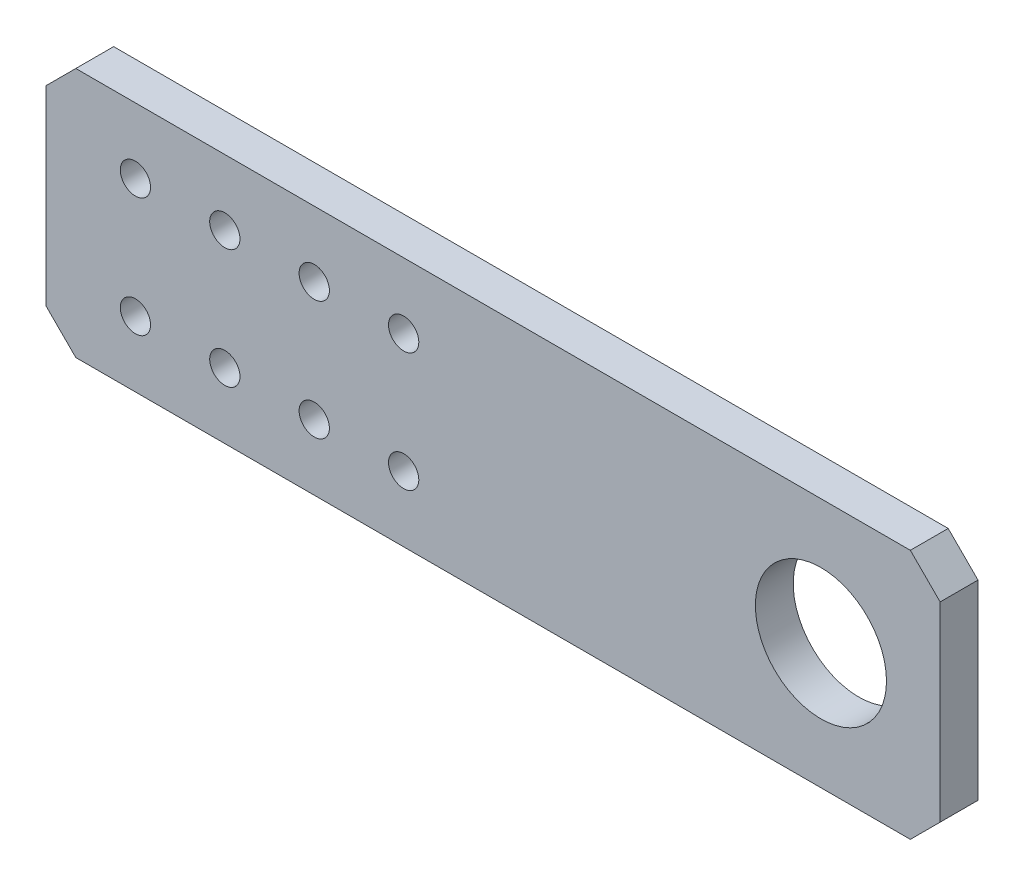
from build123d import *

# Parameters (mm, degrees)
SKETCH1_W           = 200
SKETCH1_H           = 42
BOSS_EXTRUDE1_DEPTH = 6.35
SKETCH4_R           = 2.286
CUT_EXTRUDE3_DEPTH  = 7.35
CHAMFER1_SIZE       = 5
SKETCH9_R           = 11
CUT_EXTRUDE8_DEPTH  = 7.35
SKETCH12_R          = 2.286
CUT_EXTRUDE11_DEPTH = 7.35
SKETCH13_R          = 2.286
SKETCH13_R_2        = 2.54
CUT_EXTRUDE12_DEPTH = 10


with BuildPart() as part:
    # Sketch1 → Boss-Extrude1 (new body)
    with BuildSketch(Plane.XY):
        Rectangle(SKETCH1_W, SKETCH1_H)
    extrude(amount=BOSS_EXTRUDE1_DEPTH)

    # Sketch4 → Cut-Extrude3 (cut, through all)
    with BuildSketch(Plane.XY.offset(6.35)):
        with Locations((-76, 0)):
            Circle(SKETCH4_R)
    extrude(amount=-CUT_EXTRUDE3_DEPTH, mode=Mode.SUBTRACT)

    # Chamfer1
    chamfer1_edges = [part.edges().sort_by_distance(p)[0] for p in [
        (100, -21, 3.175),
        (-100, -21, 3.175),
        (-100, 21, 3.175),
        (100, 21, 3.175),
    ]]
    chamfer(chamfer1_edges, length=CHAMFER1_SIZE)

    # Sketch9 → Cut-Extrude8 (cut, through all)
    with BuildSketch(Plane.XY.offset(6.35)):
        with Locations((80, 0)):
            Circle(SKETCH9_R)
    extrude(amount=-CUT_EXTRUDE8_DEPTH, mode=Mode.SUBTRACT)

    # Sketch12 → Cut-Extrude11 (cut, through all)
    with BuildSketch(Plane.XY.offset(6.35)):
        with Locations((-93, 0)):
            Circle(SKETCH12_R)
    extrude(amount=-CUT_EXTRUDE11_DEPTH, mode=Mode.SUBTRACT)

    # Sketch13 → Cut-Extrude12 (cut)
    with BuildSketch(Plane.XY.offset(6.35)):
        Polygon((-50, -16), (-50, 16), (-45, 21), (-95, 21), (-100, 16), (-100, -16), (-95, -21), (-45, -21), align=None)
        with Locations((-93, 0)):
            Circle(SKETCH13_R, mode=Mode.SUBTRACT)
        with Locations((-76, 0)):
            Circle(SKETCH13_R, mode=Mode.SUBTRACT)
        with Locations((-35, 10)):
            Circle(SKETCH13_R_2)
        with Locations((-35, -10)):
            Circle(SKETCH13_R_2)
        with Locations((-20, 10)):
            Circle(SKETCH13_R_2)
        with Locations((-20, -10)):
            Circle(SKETCH13_R_2)
        with Locations((-5, 10)):
            Circle(SKETCH13_R_2)
        with Locations((-5, -10)):
            Circle(SKETCH13_R_2)
        with Locations((10, 10)):
            Circle(SKETCH13_R_2)
        with Locations((10, -10)):
            Circle(SKETCH13_R_2)
    extrude(amount=-CUT_EXTRUDE12_DEPTH, mode=Mode.SUBTRACT)


solid = part.part
